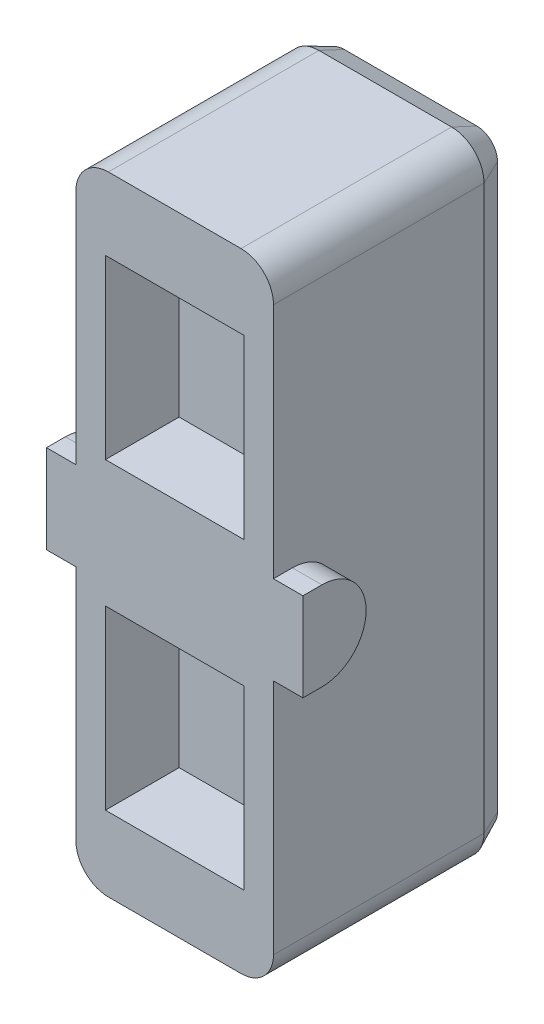
from build123d import *

# Parameters (mm, degrees)
BOSS_EXTRU_1_DEPTH      = 8
CHANFREIN1_SIZE         = 0.4
CHANFREIN1_SIZE2        = 0.857802768
BOSS_EXTRU_2_DEPTH      = 0.2
ENL_V_MAT_EXTRU_3_DEPTH = 0.2
ESQUISSE3_W             = 4.7
ESQUISSE3_H             = 6
ENL_V_MAT_EXTRU_4_DEPTH = 2.5
BOSS_EXTRU_3_DEPTH      = 1
BOSS_EXTRU_3_DEPTH_BACK = 7.7


with BuildPart() as part:
    # Esquisse2 → Boss.-Extru.1 (new body)
    with BuildSketch(Plane.XY):
        with BuildLine():
            Line((1.1, 0), (5.6, 0))
            ThreePointArc((5.6, 0), (6.377817459, 0.322182541), (6.7, 1.1))
            Line((6.7, 1.1), (6.7, 20.2))
            ThreePointArc((6.7, 20.2), (6.377817459, 20.977817459), (5.6, 21.3))
            Line((5.6, 21.3), (1.1, 21.3))
            ThreePointArc((1.1, 21.3), (0.322182541, 20.977817459), (0, 20.2))
            Line((0, 20.2), (0, 1.1))
            ThreePointArc((0, 1.1), (0.322182541, 0.322182541), (1.1, 0))
        make_face()
    extrude(amount=BOSS_EXTRU_1_DEPTH)

    # Chanfrein1
    chanfrein1_edges = [part.edges().sort_by_distance(p)[0] for p in [
        (3.35, 0, 0),
        (6.377817459, 0.322182541, 0),
        (0.322182541, 0.322182541, 0),
        (6.7, 10.65, 0),
        (0, 10.65, 0),
        (6.377817459, 20.977817459, 0),
        (0.322182541, 20.977817459, 0),
        (3.35, 21.3, 0),
    ]]
    chanfrein1_side = [part.faces().sort_by_distance(p)[0] for p in [
        (3.35, 10.65, 0),
    ]]
    chamfer(chanfrein1_edges, length=CHANFREIN1_SIZE, length2=CHANFREIN1_SIZE2, reference=chanfrein1_side[0])

    # Esquisse5_4 → Boss.-Extru.2 (add)
    # profile 1 of 5: a face of its own
    with BuildSketch(Plane.XY):
        Polygon((1.54, 5.9), (5.159538913, 5.9), (3.349812525, 1.9), align=None)
        Polygon((3.349799516, 3.355553525), (2.47002862, 5.3), (4.22952854, 5.3), align=None, mode=Mode.SUBTRACT)
    # profile 2 of 5: a face of its own
    with BuildSketch(Plane.XY):
        Polygon((1.54, 15.4), (5.16, 15.4), (3.35, 19.4), align=None)
        Polygon((2.470068334, 16), (4.229931666, 16), (3.35, 17.944600368), align=None, mode=Mode.SUBTRACT)
    # profile 3 of 5: a face of its own
    with BuildSketch(Plane.XY):
        with BuildLine():
            Line((6.075641026, 12.154141058), (5.672495994, 12.154141058))
            add(Edge.make_bspline(
                [(5.672495994, 12.154141058), (5.645948647, 12.154012027), (5.594664895, 12.153762766), (5.520846736, 12.150099205), (5.452824564, 12.144815903), (5.390935151, 12.137038821), (5.334959658, 12.126428187), (5.284909464, 12.114080553), (5.24046632, 12.099897584), (5.18953241, 12.07697466), (5.132296791, 12.041136993), (5.071993442, 11.985766647), (5.018549496, 11.918844398), (4.973038306, 11.840588225), (4.935164328, 11.753037211), (4.909144562, 11.656548858), (4.892742324, 11.552737932), (4.890762826, 11.480961988), (4.88974359, 11.44400484)],
                knots=[0, 0, 0, 0, 1.039627727, 2.00833668, 2.893894799, 3.711330588, 4.449924537, 5.123848414, 5.729630637, 6.273977409, 7.307977519, 8.358648022, 9.465487059, 10.649573196, 11.894375491, 13.190322934, 14.553308434, 16, 16, 16, 16], degree=3))
            add(Edge.make_bspline(
                [(4.88974359, 11.44400484), (4.890088186, 11.424303767), (4.890763496, 11.3856953), (4.894405149, 11.328937122), (4.902447592, 11.274910878), (4.911421441, 11.22287395), (4.924637103, 11.173619713), (4.940192748, 11.12656556), (4.958464694, 11.082038992), (4.980453546, 11.040316834), (5.004097786, 11.000571368), (5.03163336, 10.963825262), (5.06139783, 10.929306025), (5.094438696, 10.897532378), (5.129948427, 10.867873601), (5.168696197, 10.840832359), (5.210228289, 10.816226574), (5.239526977, 10.802101514), (5.254326923, 10.794966378)],
                knots=[0, 0, 0, 0, 1.194053423, 2.340003074, 3.442999494, 4.502508745, 5.537936761, 6.529597532, 7.50460804, 8.450208031, 9.385306774, 10.303844016, 11.228820201, 12.144512199, 13.078351622, 14.029723606, 15.004734115, 16, 16, 16, 16], degree=3))
            Line((5.254326923, 10.794966378), (4.809615385, 9.654141058))
            Line((4.809615385, 9.654141058), (5.204246795, 9.654141058))
            Line((5.204246795, 9.654141058), (5.628425481, 10.743884648))
            Line((5.628425481, 10.743884648), (5.723076923, 10.743884648))
            Line((5.723076923, 10.743884648), (5.723076923, 9.654141058))
            Line((5.723076923, 9.654141058), (6.075641026, 9.654141058))
            Line((6.075641026, 9.654141058), (6.075641026, 12.154141058))
        make_face()
        with BuildLine():
            Line((5.723076923, 11.192602596), (5.591866987, 11.192602596))
            add(Edge.make_bspline(
                [(5.591866987, 11.192602596), (5.575840463, 11.19284479), (5.545102457, 11.193309304), (5.500922008, 11.195431736), (5.460829482, 11.200609301), (5.424574142, 11.207146823), (5.391825112, 11.214648868), (5.363307046, 11.225398701), (5.338322299, 11.2371536), (5.310750554, 11.256080029), (5.281865863, 11.286059344), (5.258220961, 11.332500815), (5.244318315, 11.38828652), (5.243006542, 11.428559128), (5.242307692, 11.450014455)],
                knots=[0, 0, 0, 0, 1.14443165, 2.194958024, 3.155864406, 4.02787753, 4.825710302, 5.549708663, 6.200008757, 6.791751392, 7.929772656, 9.129352395, 10.470655706, 12, 12, 12, 12], degree=3))
            add(Edge.make_bspline(
                [(5.242307692, 11.450014455), (5.242799026, 11.463235795), (5.243757826, 11.4890362), (5.250907237, 11.526264589), (5.262353723, 11.560992713), (5.279053681, 11.592297793), (5.299015388, 11.620652732), (5.322674116, 11.644858939), (5.349557891, 11.664649446), (5.381004798, 11.680719968), (5.420813219, 11.692219935), (5.471888785, 11.700207675), (5.535860062, 11.704849784), (5.582844419, 11.705221162), (5.608393429, 11.705423109)],
                knots=[0, 0, 0, 0, 0.924337365, 1.803771715, 2.642005932, 3.472477419, 4.2760797, 5.0605346, 5.828920279, 6.601817847, 7.517857049, 8.713834682, 10.213058996, 12, 12, 12, 12], degree=3))
            Line((5.608393429, 11.705423109), (5.723076923, 11.705423109))
            Line((5.723076923, 11.705423109), (5.723076923, 11.192602596))
        make_face(mode=Mode.SUBTRACT)
    # profile 4 of 5: a face of its own
    with BuildSketch(Plane.XY):
        Polygon((4.505128205, 12.154141058), (4.172596154, 12.154141058), (3.319230769, 10.509008846), (3.319230769, 12.154141058), (2.966666667, 12.154141058), (2.966666667, 9.654141058), (3.301702724, 9.654141058), (4.152564103, 11.294265257), (4.152564103, 9.654141058), (4.505128205, 9.654141058), align=None)
    # profile 5 of 5: a face of its own
    with BuildSketch(Plane.XY):
        with BuildLine():
            Line((0.731089744, 11.75650484), (0.995012019, 11.431484808))
            add(Edge.make_bspline(
                [(0.995012019, 11.431484808), (1.015921934, 11.458244882), (1.056394931, 11.510041383), (1.122905185, 11.579260941), (1.192184692, 11.637767517), (1.26416915, 11.685861676), (1.338949153, 11.723479342), (1.416391074, 11.750167834), (1.496659001, 11.766203406), (1.550996525, 11.768410662), (1.578445513, 11.769525673)],
                knots=[0, 0, 0, 0, 1.162569996, 2.250257521, 3.280960514, 4.262508183, 5.208546176, 6.139695973, 7.060254147, 8, 8, 8, 8], degree=3))
            add(Edge.make_bspline(
                [(1.578445513, 11.769525673), (1.602192158, 11.76872068), (1.649133138, 11.767129417), (1.718004379, 11.755549379), (1.783752958, 11.73560282), (1.846756722, 11.708767663), (1.906207915, 11.672942199), (1.963211907, 11.630279159), (2.016790273, 11.57923519), (2.066902307, 11.521425734), (2.112749006, 11.458403302), (2.15242626, 11.390872015), (2.185975691, 11.320105216), (2.21381991, 11.245941862), (2.235054055, 11.168445486), (2.250860914, 11.087636066), (2.259822159, 11.003504551), (2.260960672, 10.946228928), (2.261538462, 10.917161891)],
                knots=[0, 0, 0, 0, 0.938427293, 1.855028254, 2.750559532, 3.649002957, 4.554277097, 5.487260679, 6.458112854, 7.472967846, 8.507704688, 9.534076982, 10.56411184, 11.599710848, 12.661054299, 13.736395705, 14.851234316, 16, 16, 16, 16], degree=3))
            add(Edge.make_bspline(
                [(2.261538462, 10.917161891), (2.261073579, 10.887082451), (2.260159165, 10.827916933), (2.249605751, 10.741054213), (2.23369087, 10.65768359), (2.211916725, 10.57753948), (2.182495261, 10.501328626), (2.14747737, 10.428280037), (2.105709315, 10.358865616), (2.057811913, 10.29393755), (2.00612242, 10.233819413), (1.949438213, 10.182323226), (1.890885409, 10.137305562), (1.828195764, 10.101984998), (1.763241727, 10.073367077), (1.695080376, 10.053410729), (1.623974546, 10.040961515), (1.575492416, 10.039498506), (1.550901442, 10.038756443)],
                knots=[0, 0, 0, 0, 1.148957322, 2.259970722, 3.338473738, 4.390945319, 5.428834093, 6.456021376, 7.483367133, 8.51947018, 9.536703863, 10.507423661, 11.441391095, 12.352953102, 13.250114251, 14.148363472, 15.060817986, 16, 16, 16, 16], degree=3))
            add(Edge.make_bspline(
                [(1.550901442, 10.038756443), (1.534856632, 10.038941734), (1.503333582, 10.039305773), (1.457165589, 10.045231662), (1.412983625, 10.053663784), (1.370425389, 10.065029292), (1.330148116, 10.08064349), (1.291580319, 10.099345705), (1.254977082, 10.121380923), (1.220254349, 10.147027005), (1.187469045, 10.176581341), (1.155931981, 10.209247024), (1.126883252, 10.246555457), (1.098592117, 10.286875914), (1.073017304, 10.331868834), (1.047471498, 10.3796982), (1.025289776, 10.432284847), (1.011578423, 10.468731428), (1.004527244, 10.487474391)],
                knots=[0, 0, 0, 0, 1.009433297, 1.983221678, 2.925183546, 3.840502028, 4.752011326, 5.640384745, 6.536187199, 7.437950061, 8.35350986, 9.312439097, 10.292333503, 11.327268651, 12.410594007, 13.548179697, 14.73913061, 16, 16, 16, 16], degree=3))
            Line((1.004527244, 10.487474391), (1.556410256, 10.487474391))
            Line((1.556410256, 10.487474391), (1.556410256, 10.93619234))
            Line((1.556410256, 10.93619234), (0.597375801, 10.93619234))
            Line((0.597375801, 10.93619234), (0.594871795, 10.829521667))
            add(Edge.make_bspline(
                [(0.594871795, 10.829521667), (0.59527027, 10.802135312), (0.596065745, 10.747464044), (0.602058607, 10.666017756), (0.61273573, 10.585650527), (0.62721881, 10.506408554), (0.645844508, 10.428202764), (0.668147004, 10.350995204), (0.695598381, 10.275115011), (0.726281643, 10.200723495), (0.760044801, 10.128927383), (0.796751426, 10.06110302), (0.835667083, 9.99742886), (0.877285395, 9.938187768), (0.921378582, 9.883405249), (0.96803215, 9.833333855), (1.01689258, 9.787289107), (1.068258044, 9.74589155), (1.12204423, 9.708968052), (1.178383847, 9.677553653), (1.236513741, 9.650281195), (1.296991808, 9.628142003), (1.359822334, 9.611034477), (1.425030964, 9.599325587), (1.492446746, 9.59137451), (1.538191021, 9.590488418), (1.561418269, 9.590038494)],
                knots=[0, 0, 0, 0, 1.128009698, 2.251841139, 3.361446829, 4.466013101, 5.568437079, 6.671632761, 7.774314034, 8.890356461, 9.985357348, 11.04064822, 12.065458456, 13.057448214, 14.020710771, 14.959715157, 15.874257383, 16.783823037, 17.674478921, 18.55807308, 19.437886768, 20.316732623, 21.20746813, 22.116461811, 23.043609094, 24, 24, 24, 24], degree=3))
            add(Edge.make_bspline(
                [(1.561418269, 9.590038494), (1.586313125, 9.590473297), (1.635567852, 9.591333559), (1.708416023, 9.599593852), (1.779049704, 9.613073288), (1.847643242, 9.631816124), (1.914400365, 9.655248168), (1.979150303, 9.684259069), (2.041435439, 9.719344326), (2.102016827, 9.758533079), (2.159574973, 9.803350993), (2.214330858, 9.852527836), (2.265957634, 9.906324496), (2.314733807, 9.964379381), (2.359509853, 10.027453285), (2.402623448, 10.094014993), (2.441339241, 10.165943955), (2.477331484, 10.241577332), (2.509078218, 10.320469876), (2.537118093, 10.401198237), (2.561487642, 10.48328353), (2.580215804, 10.567203648), (2.595309772, 10.652422776), (2.606367362, 10.739142945), (2.613070955, 10.82741098), (2.613757044, 10.886768292), (2.614102564, 10.91666109)],
                knots=[0, 0, 0, 0, 0.949407547, 1.878412524, 2.792654211, 3.690220038, 4.58853108, 5.489254184, 6.392944044, 7.3131988, 8.23925243, 9.172699515, 10.118512105, 11.08147073, 12.062371635, 13.06755144, 14.104877296, 15.175960345, 16.261560333, 17.347104283, 18.435316132, 19.526003456, 20.625338713, 21.735923335, 22.859793629, 24, 24, 24, 24], degree=3))
            add(Edge.make_bspline(
                [(2.614102564, 10.91666109), (2.613357406, 10.957423611), (2.611888192, 11.037794238), (2.599517081, 11.156285464), (2.579674438, 11.27081282), (2.55149318, 11.381074636), (2.516009699, 11.487598015), (2.471657799, 11.589532885), (2.42025762, 11.688264689), (2.379292185, 11.750001532), (2.35869391, 11.781044103)],
                knots=[0, 0, 0, 0, 1.068286482, 2.10631857, 3.119254948, 4.112645344, 5.086824908, 6.059017212, 7.024033399, 8, 8, 8, 8], degree=3))
            add(Edge.make_bspline(
                [(2.35869391, 11.781044103), (2.346039521, 11.798889777), (2.321091216, 11.834072772), (2.280803167, 11.88344671), (2.239811843, 11.930011278), (2.196673148, 11.972335157), (2.152408361, 12.011653687), (2.106906036, 12.047807215), (2.059731732, 12.080436683), (2.011051102, 12.109547178), (1.960885379, 12.135228082), (1.909179117, 12.15699601), (1.856585578, 12.176520557), (1.802162533, 12.191170139), (1.746565779, 12.203486917), (1.689300191, 12.211656028), (1.630657114, 12.21768786), (1.590981746, 12.218057062), (1.570933494, 12.218243622)],
                knots=[0, 0, 0, 0, 1.116341401, 2.200882561, 3.250969899, 4.28126982, 5.283240038, 6.271971392, 7.245756979, 8.20874655, 9.165230382, 10.119586497, 11.071047385, 12.026125935, 12.993778557, 13.975879, 14.97719687, 16, 16, 16, 16], degree=3))
            add(Edge.make_bspline(
                [(1.570933494, 12.218243622), (1.549886595, 12.217837497), (1.508222304, 12.217033534), (1.446201683, 12.211236862), (1.385088944, 12.202484694), (1.32510363, 12.189287107), (1.266123291, 12.172885053), (1.208441011, 12.151968446), (1.151379388, 12.12834376), (1.11458492, 12.109488983), (1.096173878, 12.100054519)],
                knots=[0, 0, 0, 0, 1.021908586, 2.022963016, 3.022637993, 4.017965106, 5.003406046, 5.993105494, 6.995799654, 8, 8, 8, 8], degree=3))
            add(Edge.make_bspline(
                [(1.096173878, 12.100054519), (1.08047469, 12.091319969), (1.048414904, 12.073482879), (1.002642209, 12.040793101), (0.956340301, 12.004752927), (0.91013366, 11.964164436), (0.864866503, 11.918474904), (0.819648645, 11.868631724), (0.774461744, 11.814675747), (0.745760612, 11.776181537), (0.731089744, 11.75650484)],
                knots=[0, 0, 0, 0, 0.852576279, 1.741071806, 2.667250814, 3.639030165, 4.659304158, 5.720020043, 6.834565662, 8, 8, 8, 8], degree=3))
        make_face()
    extrude(amount=-BOSS_EXTRU_2_DEPTH)

    # Esquisse5 → Enlèv. mat.-Extru.3 (cut)
    # profile 1 of 5: a face of its own
    with BuildSketch(Plane.XY):
        Polygon((1.54, 5.9), (5.159538913, 5.9), (3.349812525, 1.9), align=None)
        Polygon((3.349799516, 3.355553525), (2.47002862, 5.3), (4.22952854, 5.3), align=None, mode=Mode.SUBTRACT)
    # profile 2 of 5: a face of its own
    with BuildSketch(Plane.XY):
        Polygon((1.54, 15.4), (5.16, 15.4), (3.35, 19.4), align=None)
        Polygon((2.470068334, 16), (4.229931666, 16), (3.35, 17.944600368), align=None, mode=Mode.SUBTRACT)
    # profile 3 of 5: a face of its own
    with BuildSketch(Plane.XY):
        with BuildLine():
            Line((6.075641026, 12.154141058), (5.672495994, 12.154141058))
            add(Edge.make_bspline(
                [(5.672495994, 12.154141058), (5.645948647, 12.154012027), (5.594664895, 12.153762766), (5.520846736, 12.150099205), (5.452824564, 12.144815903), (5.390935151, 12.137038821), (5.334959658, 12.126428187), (5.284909464, 12.114080553), (5.24046632, 12.099897584), (5.18953241, 12.07697466), (5.132296791, 12.041136993), (5.071993442, 11.985766647), (5.018549496, 11.918844398), (4.973038306, 11.840588225), (4.935164328, 11.753037211), (4.909144562, 11.656548858), (4.892742324, 11.552737932), (4.890762826, 11.480961988), (4.88974359, 11.44400484)],
                knots=[0, 0, 0, 0, 1.039627727, 2.00833668, 2.893894799, 3.711330588, 4.449924537, 5.123848414, 5.729630637, 6.273977409, 7.307977519, 8.358648022, 9.465487059, 10.649573196, 11.894375491, 13.190322934, 14.553308434, 16, 16, 16, 16], degree=3))
            add(Edge.make_bspline(
                [(4.88974359, 11.44400484), (4.890088186, 11.424303767), (4.890763496, 11.3856953), (4.894405149, 11.328937122), (4.902447592, 11.274910878), (4.911421441, 11.22287395), (4.924637103, 11.173619713), (4.940192748, 11.12656556), (4.958464694, 11.082038992), (4.980453546, 11.040316834), (5.004097786, 11.000571368), (5.03163336, 10.963825262), (5.06139783, 10.929306025), (5.094438696, 10.897532378), (5.129948427, 10.867873601), (5.168696197, 10.840832359), (5.210228289, 10.816226574), (5.239526977, 10.802101514), (5.254326923, 10.794966378)],
                knots=[0, 0, 0, 0, 1.194053423, 2.340003074, 3.442999494, 4.502508745, 5.537936761, 6.529597532, 7.50460804, 8.450208031, 9.385306774, 10.303844016, 11.228820201, 12.144512199, 13.078351622, 14.029723606, 15.004734115, 16, 16, 16, 16], degree=3))
            Line((5.254326923, 10.794966378), (4.809615385, 9.654141058))
            Line((4.809615385, 9.654141058), (5.204246795, 9.654141058))
            Line((5.204246795, 9.654141058), (5.628425481, 10.743884648))
            Line((5.628425481, 10.743884648), (5.723076923, 10.743884648))
            Line((5.723076923, 10.743884648), (5.723076923, 9.654141058))
            Line((5.723076923, 9.654141058), (6.075641026, 9.654141058))
            Line((6.075641026, 9.654141058), (6.075641026, 12.154141058))
        make_face()
        with BuildLine():
            Line((5.723076923, 11.192602596), (5.591866987, 11.192602596))
            add(Edge.make_bspline(
                [(5.591866987, 11.192602596), (5.575840463, 11.19284479), (5.545102457, 11.193309304), (5.500922008, 11.195431736), (5.460829482, 11.200609301), (5.424574142, 11.207146823), (5.391825112, 11.214648868), (5.363307046, 11.225398701), (5.338322299, 11.2371536), (5.310750554, 11.256080029), (5.281865863, 11.286059344), (5.258220961, 11.332500815), (5.244318315, 11.38828652), (5.243006542, 11.428559128), (5.242307692, 11.450014455)],
                knots=[0, 0, 0, 0, 1.14443165, 2.194958024, 3.155864406, 4.02787753, 4.825710302, 5.549708663, 6.200008757, 6.791751392, 7.929772656, 9.129352395, 10.470655706, 12, 12, 12, 12], degree=3))
            add(Edge.make_bspline(
                [(5.242307692, 11.450014455), (5.242799026, 11.463235795), (5.243757826, 11.4890362), (5.250907237, 11.526264589), (5.262353723, 11.560992713), (5.279053681, 11.592297793), (5.299015388, 11.620652732), (5.322674116, 11.644858939), (5.349557891, 11.664649446), (5.381004798, 11.680719968), (5.420813219, 11.692219935), (5.471888785, 11.700207675), (5.535860062, 11.704849784), (5.582844419, 11.705221162), (5.608393429, 11.705423109)],
                knots=[0, 0, 0, 0, 0.924337365, 1.803771715, 2.642005932, 3.472477419, 4.2760797, 5.0605346, 5.828920279, 6.601817847, 7.517857049, 8.713834682, 10.213058996, 12, 12, 12, 12], degree=3))
            Line((5.608393429, 11.705423109), (5.723076923, 11.705423109))
            Line((5.723076923, 11.705423109), (5.723076923, 11.192602596))
        make_face(mode=Mode.SUBTRACT)
    # profile 4 of 5: a face of its own
    with BuildSketch(Plane.XY):
        Polygon((4.505128205, 12.154141058), (4.172596154, 12.154141058), (3.319230769, 10.509008846), (3.319230769, 12.154141058), (2.966666667, 12.154141058), (2.966666667, 9.654141058), (3.301702724, 9.654141058), (4.152564103, 11.294265257), (4.152564103, 9.654141058), (4.505128205, 9.654141058), align=None)
    # profile 5 of 5: a face of its own
    with BuildSketch(Plane.XY):
        with BuildLine():
            Line((0.731089744, 11.75650484), (0.995012019, 11.431484808))
            add(Edge.make_bspline(
                [(0.995012019, 11.431484808), (1.015921934, 11.458244882), (1.056394931, 11.510041383), (1.122905185, 11.579260941), (1.192184692, 11.637767517), (1.26416915, 11.685861676), (1.338949153, 11.723479342), (1.416391074, 11.750167834), (1.496659001, 11.766203406), (1.550996525, 11.768410662), (1.578445513, 11.769525673)],
                knots=[0, 0, 0, 0, 1.162569996, 2.250257521, 3.280960514, 4.262508183, 5.208546176, 6.139695973, 7.060254147, 8, 8, 8, 8], degree=3))
            add(Edge.make_bspline(
                [(1.578445513, 11.769525673), (1.602192158, 11.76872068), (1.649133138, 11.767129417), (1.718004379, 11.755549379), (1.783752958, 11.73560282), (1.846756722, 11.708767663), (1.906207915, 11.672942199), (1.963211907, 11.630279159), (2.016790273, 11.57923519), (2.066902307, 11.521425734), (2.112749006, 11.458403302), (2.15242626, 11.390872015), (2.185975691, 11.320105216), (2.21381991, 11.245941862), (2.235054055, 11.168445486), (2.250860914, 11.087636066), (2.259822159, 11.003504551), (2.260960672, 10.946228928), (2.261538462, 10.917161891)],
                knots=[0, 0, 0, 0, 0.938427293, 1.855028254, 2.750559532, 3.649002957, 4.554277097, 5.487260679, 6.458112854, 7.472967846, 8.507704688, 9.534076982, 10.56411184, 11.599710848, 12.661054299, 13.736395705, 14.851234316, 16, 16, 16, 16], degree=3))
            add(Edge.make_bspline(
                [(2.261538462, 10.917161891), (2.261073579, 10.887082451), (2.260159165, 10.827916933), (2.249605751, 10.741054213), (2.23369087, 10.65768359), (2.211916725, 10.57753948), (2.182495261, 10.501328626), (2.14747737, 10.428280037), (2.105709315, 10.358865616), (2.057811913, 10.29393755), (2.00612242, 10.233819413), (1.949438213, 10.182323226), (1.890885409, 10.137305562), (1.828195764, 10.101984998), (1.763241727, 10.073367077), (1.695080376, 10.053410729), (1.623974546, 10.040961515), (1.575492416, 10.039498506), (1.550901442, 10.038756443)],
                knots=[0, 0, 0, 0, 1.148957322, 2.259970722, 3.338473738, 4.390945319, 5.428834093, 6.456021376, 7.483367133, 8.51947018, 9.536703863, 10.507423661, 11.441391095, 12.352953102, 13.250114251, 14.148363472, 15.060817986, 16, 16, 16, 16], degree=3))
            add(Edge.make_bspline(
                [(1.550901442, 10.038756443), (1.534856632, 10.038941734), (1.503333582, 10.039305773), (1.457165589, 10.045231662), (1.412983625, 10.053663784), (1.370425389, 10.065029292), (1.330148116, 10.08064349), (1.291580319, 10.099345705), (1.254977082, 10.121380923), (1.220254349, 10.147027005), (1.187469045, 10.176581341), (1.155931981, 10.209247024), (1.126883252, 10.246555457), (1.098592117, 10.286875914), (1.073017304, 10.331868834), (1.047471498, 10.3796982), (1.025289776, 10.432284847), (1.011578423, 10.468731428), (1.004527244, 10.487474391)],
                knots=[0, 0, 0, 0, 1.009433297, 1.983221678, 2.925183546, 3.840502028, 4.752011326, 5.640384745, 6.536187199, 7.437950061, 8.35350986, 9.312439097, 10.292333503, 11.327268651, 12.410594007, 13.548179697, 14.73913061, 16, 16, 16, 16], degree=3))
            Line((1.004527244, 10.487474391), (1.556410256, 10.487474391))
            Line((1.556410256, 10.487474391), (1.556410256, 10.93619234))
            Line((1.556410256, 10.93619234), (0.597375801, 10.93619234))
            Line((0.597375801, 10.93619234), (0.594871795, 10.829521667))
            add(Edge.make_bspline(
                [(0.594871795, 10.829521667), (0.59527027, 10.802135312), (0.596065745, 10.747464044), (0.602058607, 10.666017756), (0.61273573, 10.585650527), (0.62721881, 10.506408554), (0.645844508, 10.428202764), (0.668147004, 10.350995204), (0.695598381, 10.275115011), (0.726281643, 10.200723495), (0.760044801, 10.128927383), (0.796751426, 10.06110302), (0.835667083, 9.99742886), (0.877285395, 9.938187768), (0.921378582, 9.883405249), (0.96803215, 9.833333855), (1.01689258, 9.787289107), (1.068258044, 9.74589155), (1.12204423, 9.708968052), (1.178383847, 9.677553653), (1.236513741, 9.650281195), (1.296991808, 9.628142003), (1.359822334, 9.611034477), (1.425030964, 9.599325587), (1.492446746, 9.59137451), (1.538191021, 9.590488418), (1.561418269, 9.590038494)],
                knots=[0, 0, 0, 0, 1.128009698, 2.251841139, 3.361446829, 4.466013101, 5.568437079, 6.671632761, 7.774314034, 8.890356461, 9.985357348, 11.04064822, 12.065458456, 13.057448214, 14.020710771, 14.959715157, 15.874257383, 16.783823037, 17.674478921, 18.55807308, 19.437886768, 20.316732623, 21.20746813, 22.116461811, 23.043609094, 24, 24, 24, 24], degree=3))
            add(Edge.make_bspline(
                [(1.561418269, 9.590038494), (1.586313125, 9.590473297), (1.635567852, 9.591333559), (1.708416023, 9.599593852), (1.779049704, 9.613073288), (1.847643242, 9.631816124), (1.914400365, 9.655248168), (1.979150303, 9.684259069), (2.041435439, 9.719344326), (2.102016827, 9.758533079), (2.159574973, 9.803350993), (2.214330858, 9.852527836), (2.265957634, 9.906324496), (2.314733807, 9.964379381), (2.359509853, 10.027453285), (2.402623448, 10.094014993), (2.441339241, 10.165943955), (2.477331484, 10.241577332), (2.509078218, 10.320469876), (2.537118093, 10.401198237), (2.561487642, 10.48328353), (2.580215804, 10.567203648), (2.595309772, 10.652422776), (2.606367362, 10.739142945), (2.613070955, 10.82741098), (2.613757044, 10.886768292), (2.614102564, 10.91666109)],
                knots=[0, 0, 0, 0, 0.949407547, 1.878412524, 2.792654211, 3.690220038, 4.58853108, 5.489254184, 6.392944044, 7.3131988, 8.23925243, 9.172699515, 10.118512105, 11.08147073, 12.062371635, 13.06755144, 14.104877296, 15.175960345, 16.261560333, 17.347104283, 18.435316132, 19.526003456, 20.625338713, 21.735923335, 22.859793629, 24, 24, 24, 24], degree=3))
            add(Edge.make_bspline(
                [(2.614102564, 10.91666109), (2.613357406, 10.957423611), (2.611888192, 11.037794238), (2.599517081, 11.156285464), (2.579674438, 11.27081282), (2.55149318, 11.381074636), (2.516009699, 11.487598015), (2.471657799, 11.589532885), (2.42025762, 11.688264689), (2.379292185, 11.750001532), (2.35869391, 11.781044103)],
                knots=[0, 0, 0, 0, 1.068286482, 2.10631857, 3.119254948, 4.112645344, 5.086824908, 6.059017212, 7.024033399, 8, 8, 8, 8], degree=3))
            add(Edge.make_bspline(
                [(2.35869391, 11.781044103), (2.346039521, 11.798889777), (2.321091216, 11.834072772), (2.280803167, 11.88344671), (2.239811843, 11.930011278), (2.196673148, 11.972335157), (2.152408361, 12.011653687), (2.106906036, 12.047807215), (2.059731732, 12.080436683), (2.011051102, 12.109547178), (1.960885379, 12.135228082), (1.909179117, 12.15699601), (1.856585578, 12.176520557), (1.802162533, 12.191170139), (1.746565779, 12.203486917), (1.689300191, 12.211656028), (1.630657114, 12.21768786), (1.590981746, 12.218057062), (1.570933494, 12.218243622)],
                knots=[0, 0, 0, 0, 1.116341401, 2.200882561, 3.250969899, 4.28126982, 5.283240038, 6.271971392, 7.245756979, 8.20874655, 9.165230382, 10.119586497, 11.071047385, 12.026125935, 12.993778557, 13.975879, 14.97719687, 16, 16, 16, 16], degree=3))
            add(Edge.make_bspline(
                [(1.570933494, 12.218243622), (1.549886595, 12.217837497), (1.508222304, 12.217033534), (1.446201683, 12.211236862), (1.385088944, 12.202484694), (1.32510363, 12.189287107), (1.266123291, 12.172885053), (1.208441011, 12.151968446), (1.151379388, 12.12834376), (1.11458492, 12.109488983), (1.096173878, 12.100054519)],
                knots=[0, 0, 0, 0, 1.021908586, 2.022963016, 3.022637993, 4.017965106, 5.003406046, 5.993105494, 6.995799654, 8, 8, 8, 8], degree=3))
            add(Edge.make_bspline(
                [(1.096173878, 12.100054519), (1.08047469, 12.091319969), (1.048414904, 12.073482879), (1.002642209, 12.040793101), (0.956340301, 12.004752927), (0.91013366, 11.964164436), (0.864866503, 11.918474904), (0.819648645, 11.868631724), (0.774461744, 11.814675747), (0.745760612, 11.776181537), (0.731089744, 11.75650484)],
                knots=[0, 0, 0, 0, 0.852576279, 1.741071806, 2.667250814, 3.639030165, 4.659304158, 5.720020043, 6.834565662, 8, 8, 8, 8], degree=3))
        make_face()
    extrude(amount=ENL_V_MAT_EXTRU_3_DEPTH, mode=Mode.SUBTRACT)


with BuildPart() as enl_v_mat_extru_3_piece_1:
    # of the separate pieces the step leaves, piece 1, a body of its own (enl_v_mat_extru_3_pieces)
    add(part.part.solids().sort_by_distance((0, 20.2, 0.857802768))[0])

    # Esquisse3 → Enlèv. mat.-Extru.4 (cut)
    with BuildSketch(Plane.XY.offset(8)):
        with Locations((3.35, 15.8)):
            Rectangle(ESQUISSE3_W, ESQUISSE3_H)
        with Locations((3.35, 5.5)):
            Rectangle(ESQUISSE3_W, ESQUISSE3_H)
    extrude(amount=-ENL_V_MAT_EXTRU_4_DEPTH, mode=Mode.SUBTRACT)

    # Esquisse6 → Boss.-Extru.3 (add, two sides: drawn at the far end of the back side and taken through both)
    with BuildSketch(Plane.ZY.offset(-BOSS_EXTRU_3_DEPTH_BACK)):
        with BuildLine():
            Line((7.357802768, 12.15), (8, 12.15))
            Line((8, 12.15), (8, 9.15))
            Line((8, 9.15), (7.357802768, 9.15))
            ThreePointArc((7.357802768, 9.15), (5.857802768, 10.65), (7.357802768, 12.15))
        make_face()
    extrude(amount=BOSS_EXTRU_3_DEPTH + BOSS_EXTRU_3_DEPTH_BACK)


with BuildPart() as enl_v_mat_extru_3_piece_2:
    # of the separate pieces the step leaves, piece 2, a body of its own (enl_v_mat_extru_3_pieces)
    add(part.part.solids().sort_by_distance((1.54, 15.4, -0.2))[0])


with BuildPart() as enl_v_mat_extru_3_piece_3:
    # of the separate pieces the step leaves, piece 3, a body of its own (enl_v_mat_extru_3_pieces)
    add(part.part.solids().sort_by_distance((3.349812525, 1.9, -0.2))[0])


with BuildPart() as enl_v_mat_extru_3_piece_4:
    # of the separate pieces the step leaves, piece 4, a body of its own (enl_v_mat_extru_3_pieces)
    add(part.part.solids().sort_by_distance((0.731089744, 11.75650484, -0.2))[0])


with BuildPart() as enl_v_mat_extru_3_piece_5:
    # of the separate pieces the step leaves, piece 5, a body of its own (enl_v_mat_extru_3_pieces)
    add(part.part.solids().sort_by_distance((4.505128205, 12.154141058, -0.2))[0])


with BuildPart() as enl_v_mat_extru_3_piece_6:
    # of the separate pieces the step leaves, piece 6, a body of its own (enl_v_mat_extru_3_pieces)
    add(part.part.solids().sort_by_distance((6.075641026, 12.154141058, -0.2))[0])


solid = Compound([enl_v_mat_extru_3_piece_1.part, enl_v_mat_extru_3_piece_2.part, enl_v_mat_extru_3_piece_3.part, enl_v_mat_extru_3_piece_4.part, enl_v_mat_extru_3_piece_5.part, enl_v_mat_extru_3_piece_6.part])
